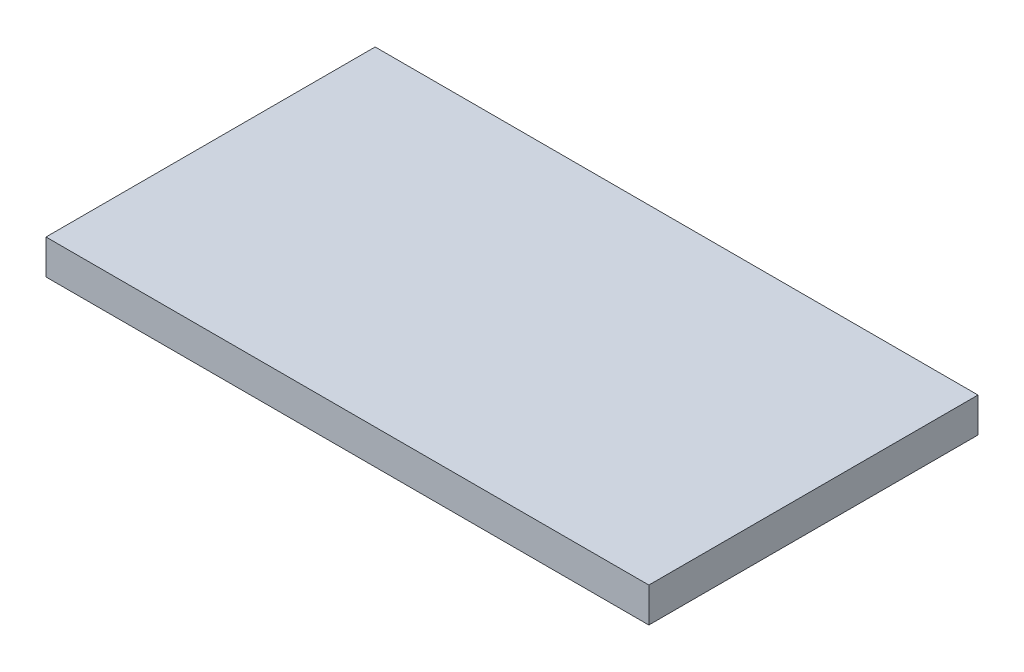
from build123d import *

# Parameters (mm, degrees)
SKETCH1_W           = 52.2
SKETCH1_H           = 28.5
SKETCH1_R           = 1
SKETCH1_W_2         = 35.320636832
SKETCH1_H_2         = 5.8
BOSS_EXTRUDE1_DEPTH = 2.5
SKETCH2_W           = 52.2
SKETCH2_H           = 28.5
BOSS_EXTRUDE2_DEPTH = 3


with BuildPart() as part:
    # Sketch1 → Boss-Extrude1 (new body)
    with BuildSketch(Plane(origin=(0, 0, 0), x_dir=(1, 0, 0), z_dir=(0, 1, 0))):
        with Locations((0, 2.55)):
            Rectangle(SKETCH1_W, SKETCH1_H)
        with Locations((-22.8, -3.2)):
            Circle(SKETCH1_R, mode=Mode.SUBTRACT)
        with Locations((22.8, -3.2)):
            Circle(SKETCH1_R, mode=Mode.SUBTRACT)
        with Locations((22.8, 8.3)):
            Circle(SKETCH1_R, mode=Mode.SUBTRACT)
        with Locations((-22.8, 8.3)):
            Circle(SKETCH1_R, mode=Mode.SUBTRACT)
        with Locations((0, -4.8)):
            Rectangle(SKETCH1_W_2, SKETCH1_H_2, mode=Mode.SUBTRACT)
        with Locations((0, 9.9)):
            Rectangle(SKETCH1_W_2, SKETCH1_H_2, mode=Mode.SUBTRACT)
    extrude(amount=BOSS_EXTRUDE1_DEPTH)

    # Sketch2 → Boss-Extrude2 (add)
    with BuildSketch(Plane.XZ):
        with Locations((0, -2.55)):
            Rectangle(SKETCH2_W, SKETCH2_H)
    extrude(amount=-BOSS_EXTRUDE2_DEPTH)


solid = part.part
